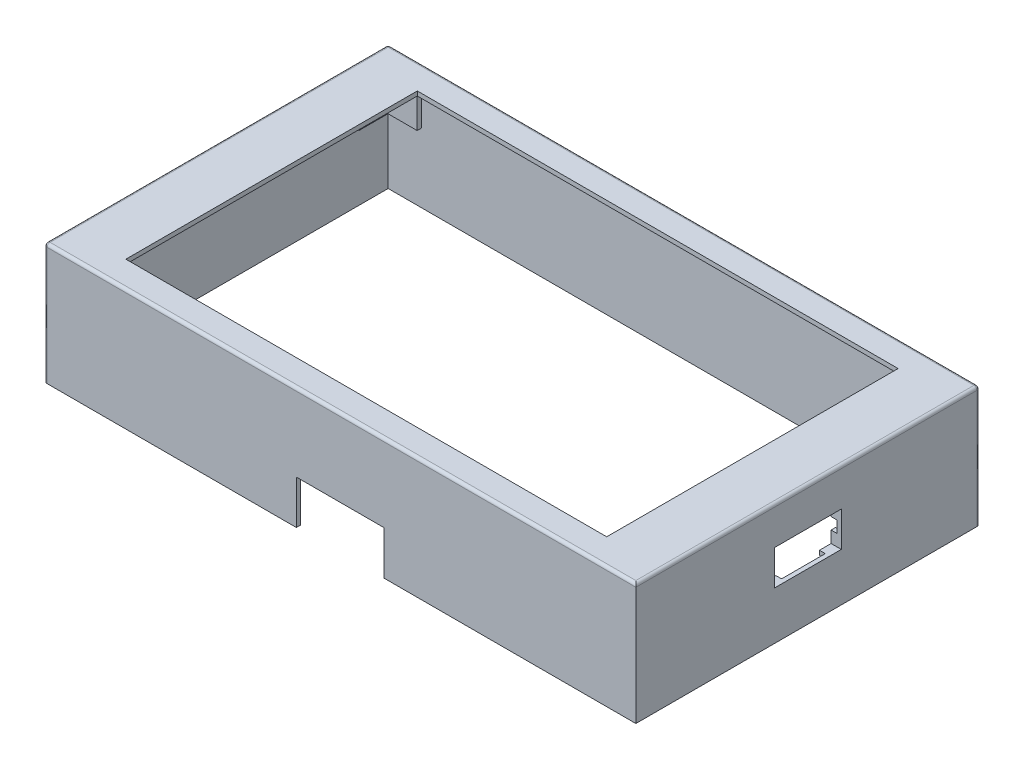
from build123d import *

# Parameters (mm, degrees)
SKETCH_1_W           = 200
SKETCH_1_H           = 115
F_40MM_DEPTH         = 40
SHELL_3_T            = 1.5
SKETCH_2_W           = 165
SKETCH_2_H           = 100
CUT_EXTRUDE_7_DEPTH  = 1.5
SKETCH_3_W           = 16
SKETCH_3_H           = 10
CUT_EXTRUDE_8_DEPTH  = 1.5
SKETCH_4_W           = 23
SKETCH_4_H           = 12
CUT_EXTRUDE_9_DEPTH  = 1.5
EXTRUDE_1_DEPTH      = 13
EXTRUDE_2_DEPTH      = 2
FILLET_2_R           = 1
SKETCH_9_W           = 30
SKETCH_9_H           = 30
CUT_EXTRUDE_10_DEPTH = 10


with BuildPart() as part:
    # 草图1 → 凸台-拉伸40mm (new body)
    with BuildSketch(Plane(origin=(0, 0, 0), x_dir=(1, 0, 0), z_dir=(0, 1, 0))):
        Rectangle(SKETCH_1_W, SKETCH_1_H)
    extrude(amount=F_40MM_DEPTH)

    # 抽壳3
    shell_3_openings = [part.faces().sort_by_distance(p)[0] for p in [
        (0, 0, 0),
    ]]
    offset(amount=SHELL_3_T, openings=shell_3_openings, kind=Kind.INTERSECTION)

    # 草图2 → 切除-拉伸7 (cut)
    with BuildSketch(Plane(origin=(0, 40, 0), x_dir=(1, 0, 0), z_dir=(0, 1, 0))):
        Rectangle(SKETCH_2_W, SKETCH_2_H)
    extrude(amount=CUT_EXTRUDE_7_DEPTH, mode=Mode.SUBTRACT)

    # 草图3 → 切除-拉伸8 (cut)
    with BuildSketch(Plane(origin=(-100, 0, 0), x_dir=(0, 0, -1), z_dir=(1, 0, 0))):
        with Locations((12, 27.5)):
            Rectangle(SKETCH_3_W, SKETCH_3_H)
    extrude(amount=-CUT_EXTRUDE_8_DEPTH, mode=Mode.SUBTRACT)

    # 草图4 → 切除-拉伸9 (cut)
    with BuildSketch(Plane.ZY.offset(-100)):
        with Locations((0, 22.5)):
            Rectangle(SKETCH_4_W, SKETCH_4_H)
    extrude(amount=-CUT_EXTRUDE_9_DEPTH, mode=Mode.SUBTRACT)

    # 草图6 → 凸台-拉伸1 (add)
    with BuildSketch(Plane(origin=(0, 40, 0), x_dir=(-1, 0, 0), z_dir=(0, -1, 0))):
        Polygon((-95.25, 52.7), (-85.25, 52.7), (-85.25, 54.2), (-96.75, 54.2), (-96.75, 42.7), (-95.25, 42.7), align=None)
        Polygon((-96.75, -42.7), (-95.25, -42.7), (-95.25, -52.7), (-85.25, -52.7), (-85.25, -54.2), (-96.75, -54.2), align=None)
        Polygon((85.25, -52.7), (85.25, -54.2), (96.75, -54.2), (96.75, -42.7), (95.25, -42.7), (95.25, -52.7), align=None)
        Polygon((85.25, 52.7), (85.25, 54.2), (96.75, 54.2), (96.75, 42.7), (95.25, 42.7), (95.25, 52.7), align=None)
    extrude(amount=EXTRUDE_1_DEPTH)

    # 草图7 → 凸台-拉伸2 (add)
    with BuildSketch(Plane.ZY.offset(-100)):
        Polygon((-7.5, 28.5), (-7.5, 30), (-13, 30), (-13, 24.5), (-11.5, 24.5), (-11.5, 28.5), align=None)
        Polygon((7.5, 28.5), (7.5, 30), (13, 30), (13, 24.5), (11.5, 24.5), (11.5, 28.5), align=None)
        Polygon((7.5, 16.5), (7.5, 15), (13, 15), (13, 20.5), (11.5, 20.5), (11.5, 16.5), align=None)
        Polygon((-13, 20.5), (-11.5, 20.5), (-11.5, 16.5), (-7.5, 16.5), (-7.5, 15), (-13, 15), align=None)
    extrude(amount=EXTRUDE_2_DEPTH)

    # 圆角2
    fillet_2_edges = [part.edges().sort_by_distance(p)[0] for p in [
        (101.5, 41.5, 0),
        (0, 41.5, -59),
        (100, 20, 57.5),
        (-101.5, 41.5, 0),
        (-101.5, 20.75, -59),
        (101.5, 20.75, -59),
        (-101.5, 20.75, 59),
        (0, 41.5, 59),
    ]]
    fillet(fillet_2_edges, radius=FILLET_2_R)

    # 草图9 → 切除-拉伸10 (cut)
    with BuildSketch(Plane(origin=(0, 0, 57.5), x_dir=(-1, 0, 0), z_dir=(0, 0, -1))):
        Rectangle(SKETCH_9_W, SKETCH_9_H)
    extrude(amount=-CUT_EXTRUDE_10_DEPTH, mode=Mode.SUBTRACT)


solid = part.part
